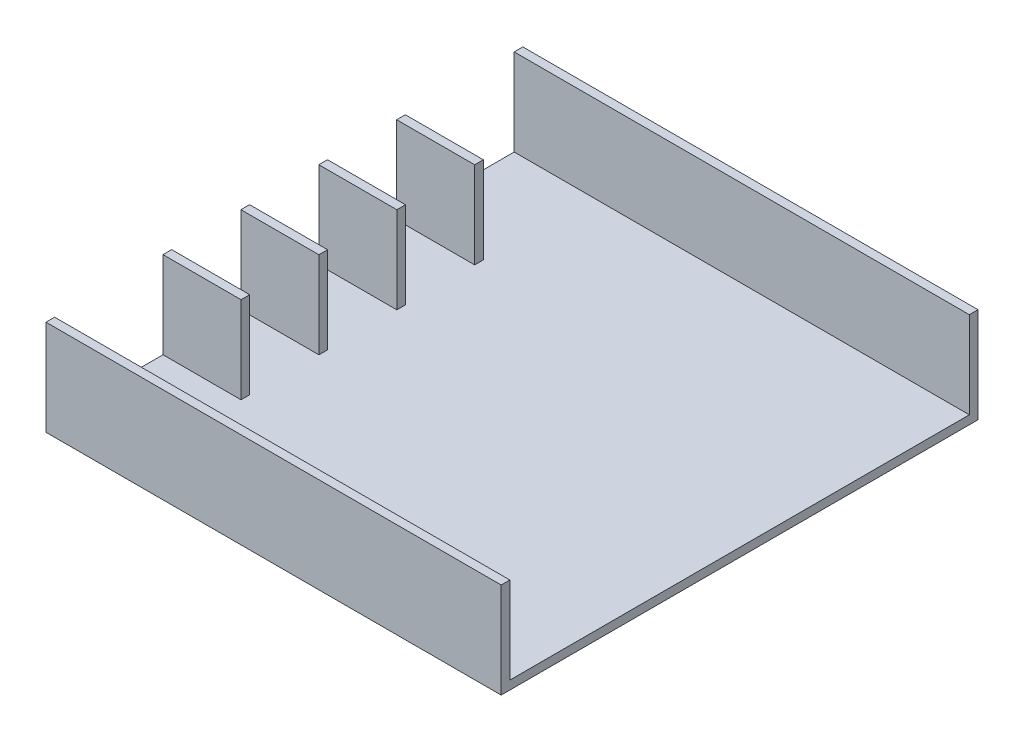
from build123d import *

# Parameters (mm, degrees)
SKETCH2_W           = 105
SKETCH2_H           = 110
BOSS_EXTRUDE1_DEPTH = 2
SKETCH4_W           = 18
SKETCH4_H           = 2
SKETCH4_W_2         = 105
BOSS_EXTRUDE2_DEPTH = 20


with BuildPart() as part:
    # Sketch2 → Boss-Extrude1 (new body)
    with BuildSketch(Plane(origin=(0, 0, 0), x_dir=(1, 0, 0), z_dir=(0, 1, 0))):
        Rectangle(SKETCH2_W, SKETCH2_H)
    extrude(amount=BOSS_EXTRUDE1_DEPTH)

    # Sketch4 → Boss-Extrude2 (add)
    with BuildSketch(Plane(origin=(0, 2, 0), x_dir=(1, 0, 0), z_dir=(0, 1, 0))):
        with Locations((-43.5, 26.895070822)):
            Rectangle(SKETCH4_W, SKETCH4_H)
        with Locations((-43.5, 8.934071448)):
            Rectangle(SKETCH4_W, SKETCH4_H)
        with Locations((-43.5, -9.04022418)):
            Rectangle(SKETCH4_W, SKETCH4_H)
        with Locations((-43.5, -27.006397159)):
            Rectangle(SKETCH4_W, SKETCH4_H)
        with Locations((0, 54)):
            Rectangle(SKETCH4_W_2, SKETCH4_H)
        with Locations((0, -54)):
            Rectangle(SKETCH4_W_2, SKETCH4_H)
    extrude(amount=BOSS_EXTRUDE2_DEPTH)


solid = part.part
